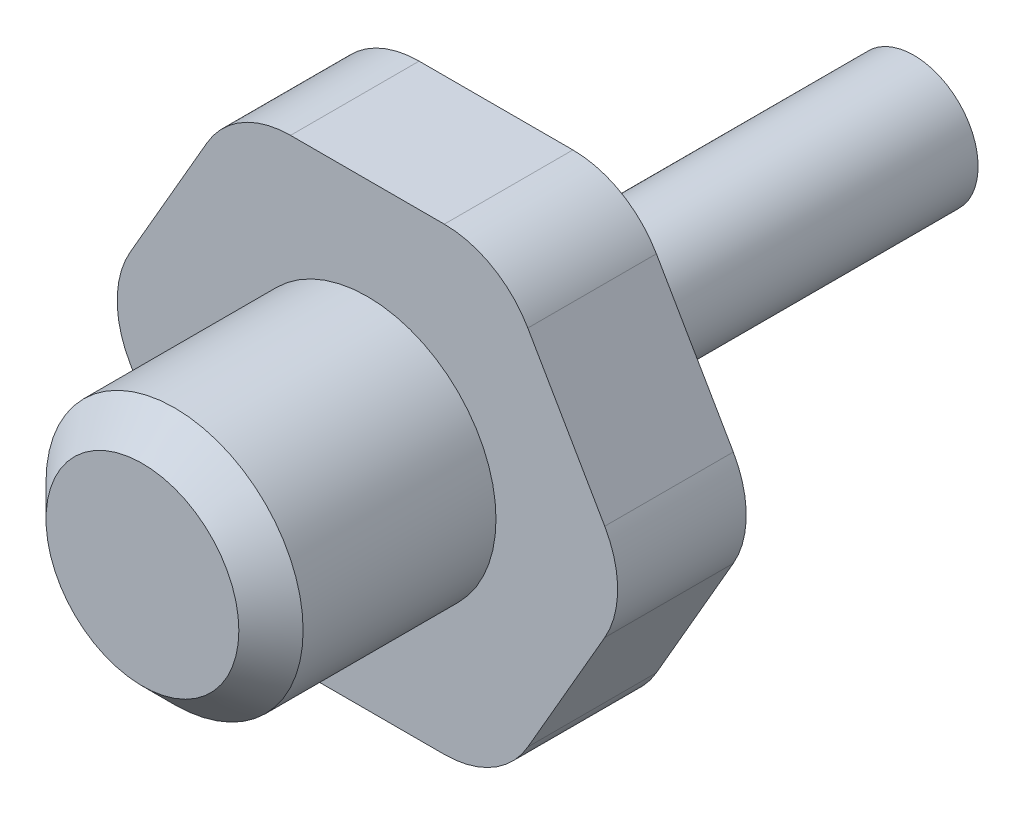
from build123d import *

# Parameters (mm, degrees)
BOSS_EXTRUDE1_DEPTH = 4
SKETCH2_R           = 4
BOSS_EXTRUDE2_DEPTH = 7
CHAMFER1_SIZE       = 1
SKETCH3_R           = 2.375
BOSS_EXTRUDE3_DEPTH = 3
SKETCH4_R           = 2
BOSS_EXTRUDE4_DEPTH = 10
FILLET2_R           = 3
FILLET3_R           = 1


with BuildPart() as part:
    # Sketch1 → Boss-Extrude1 (new body)
    with BuildSketch(Plane.XY):
        Polygon((8.248891971, 0), (4.124445986, 7.14375), (-4.124445986, 7.14375), (-8.248891971, 0), (-4.124445986, -7.14375), (4.124445986, -7.14375), align=None)
    extrude(amount=BOSS_EXTRUDE1_DEPTH)

    # Sketch2 → Boss-Extrude2 (add)
    with BuildSketch(Plane.XY.offset(4)):
        Circle(SKETCH2_R)
    extrude(amount=BOSS_EXTRUDE2_DEPTH)

    # Chamfer1
    chamfer1_edges = [part.edges().sort_by_distance(p)[0] for p in [
        (-4, 0, 11),
    ]]
    chamfer(chamfer1_edges, length=CHAMFER1_SIZE)

    # Sketch3 → Boss-Extrude3 (add)
    with BuildSketch(Plane(origin=(0, 0, 0), x_dir=(-1, 0, 0), z_dir=(0, 0, -1))):
        Circle(SKETCH3_R)
    extrude(amount=BOSS_EXTRUDE3_DEPTH)

    # Sketch4 → Boss-Extrude4 (add)
    with BuildSketch(Plane(origin=(0, 0, -3), x_dir=(-1, 0, 0), z_dir=(0, 0, -1))):
        Circle(SKETCH4_R)
    extrude(amount=BOSS_EXTRUDE4_DEPTH)

    # Fillet2
    fillet2_edges = [part.edges().sort_by_distance(p)[0] for p in [
        (4.124445986, -7.14375, 2),
        (-4.124445986, -7.14375, 2),
        (-8.248891971, 0, 2),
        (-4.124445986, 7.14375, 2),
        (4.124445986, 7.14375, 2),
        (8.248891971, 0, 2),
    ]]
    fillet(fillet2_edges, radius=FILLET2_R)

    # Fillet3
    fillet3_edges = [part.edges().sort_by_distance(p)[0] for p in [
        (2.375, 0, 0),
    ]]
    fillet(fillet3_edges, radius=FILLET3_R)


solid = part.part
